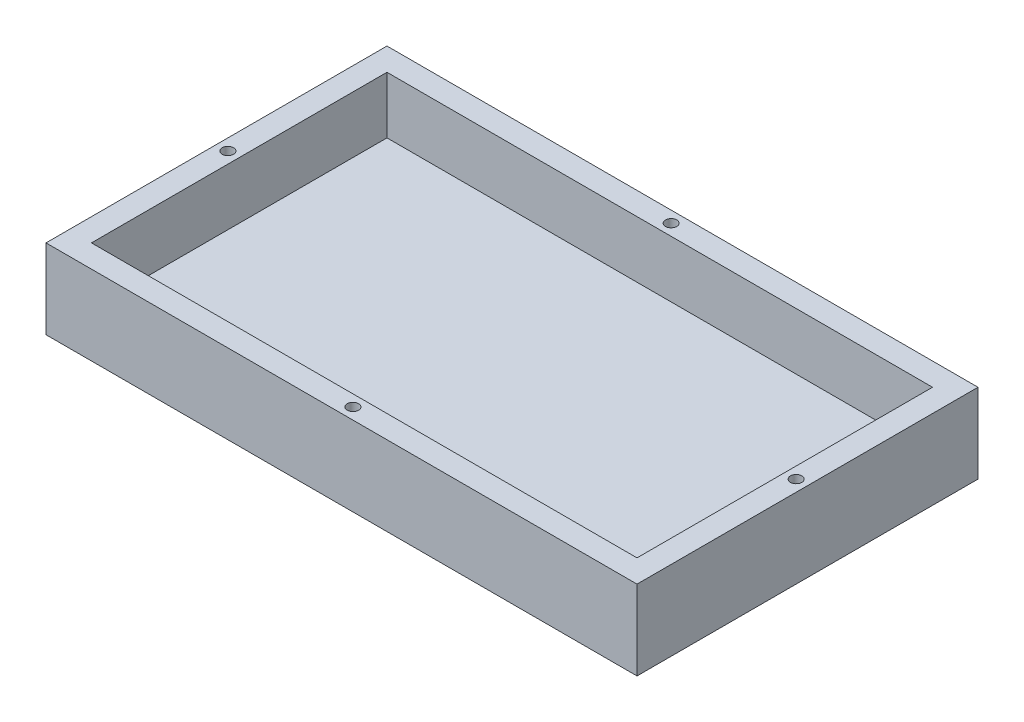
from build123d import *

# Parameters (mm, degrees)
SKETCH1_W           = 66.04
SKETCH1_H           = 38.1
BOSS_EXTRUDE3_DEPTH = 17.78
SKETCH3_W           = 60.96
SKETCH3_H           = 33.02
CUT_EXTRUDE1_DEPTH  = 15.24
SKETCH4_W           = 38.1
SKETCH4_H           = 8.89
CUT_EXTRUDE2_DEPTH  = 66.04
SKETCH5_R           = 0.635
CUT_EXTRUDE3_DEPTH  = 5.08


with BuildPart() as part:
    # Sketch1 → Boss-Extrude3 (new body)
    with BuildSketch(Plane(origin=(0, 0, 0), x_dir=(1, 0, 0), z_dir=(0, 1, 0))):
        with Locations((33.02, 19.05)):
            Rectangle(SKETCH1_W, SKETCH1_H)
    extrude(amount=BOSS_EXTRUDE3_DEPTH)

    # Sketch3 → Cut-Extrude1 (cut)
    with BuildSketch(Plane(origin=(0, 17.78, 0), x_dir=(1, 0, 0), z_dir=(0, 1, 0))):
        with Locations((33.02, 19.05)):
            Rectangle(SKETCH3_W, SKETCH3_H)
    extrude(amount=-CUT_EXTRUDE1_DEPTH, mode=Mode.SUBTRACT)

    # Sketch4 → Cut-Extrude2 (cut)
    with BuildSketch(Plane(origin=(66.04, 0, 0), x_dir=(0, 0, -1), z_dir=(1, 0, 0))):
        with Locations((19.05, 13.335)):
            Rectangle(SKETCH4_W, SKETCH4_H)
    extrude(amount=-CUT_EXTRUDE2_DEPTH, mode=Mode.SUBTRACT)

    # Sketch5 → Cut-Extrude3 (cut)
    with BuildSketch(Plane(origin=(0, 8.89, 0), x_dir=(1, 0, 0), z_dir=(0, 1, 0))):
        with Locations((33.02, 36.83)):
            Circle(SKETCH5_R)
        with Locations((33.02, 1.27)):
            Circle(SKETCH5_R)
        with Locations((1.27, 19.05)):
            Circle(SKETCH5_R)
        with Locations((64.77, 19.05)):
            Circle(SKETCH5_R)
    extrude(amount=-CUT_EXTRUDE3_DEPTH, mode=Mode.SUBTRACT)


solid = part.part
